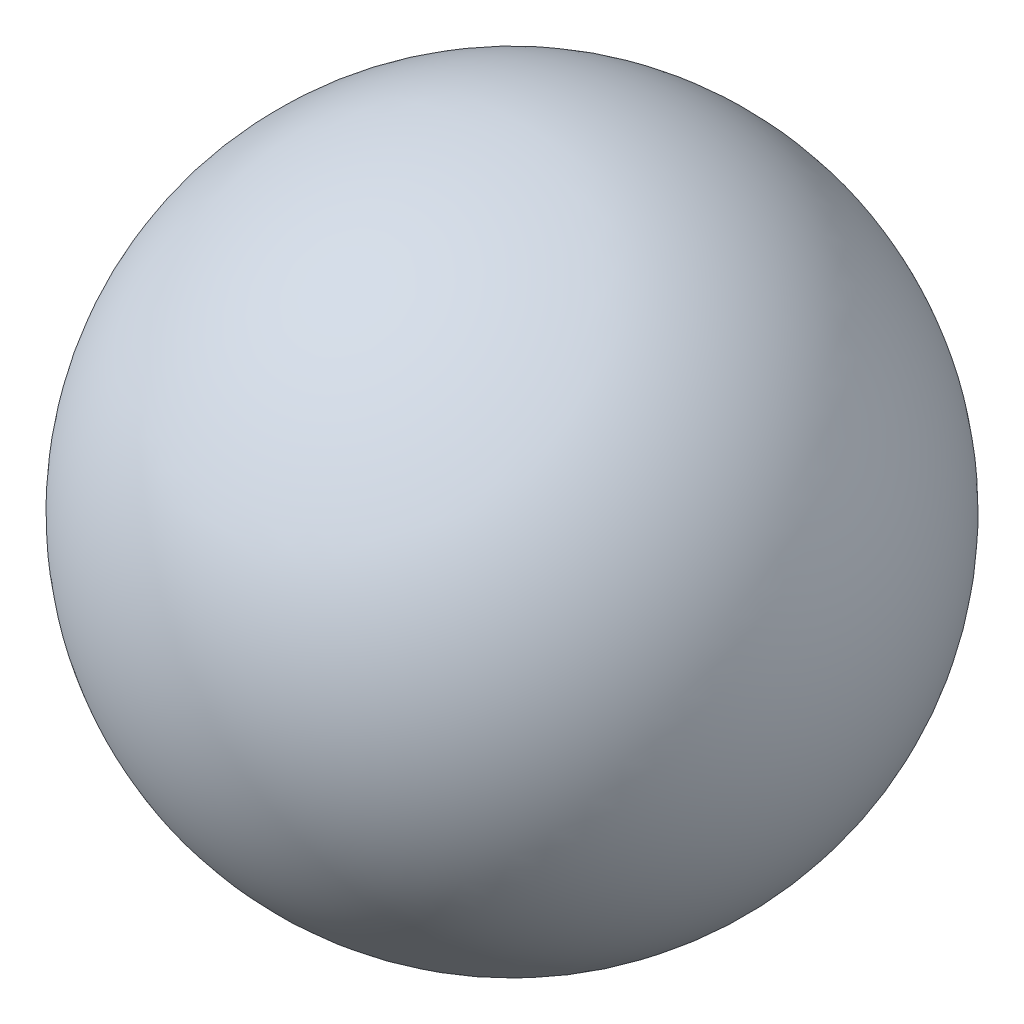
from build123d import *


with BuildPart() as part:
    # Sketch1 → Revolve1 (revolve)
    with BuildSketch(Plane(origin=(0, 0, 0), x_dir=(1, 0, 0), z_dir=(0, 1, 0))):
        with BuildLine():
            Line((1.5, 1.81), (1.5, -1.19))
            ThreePointArc((1.5, -1.19), (3, 0.31), (1.5, 1.81))
        make_face()
    revolve(axis=Axis((1.5, 0, -1.81), (0, 0, 1)))


solid = part.part
